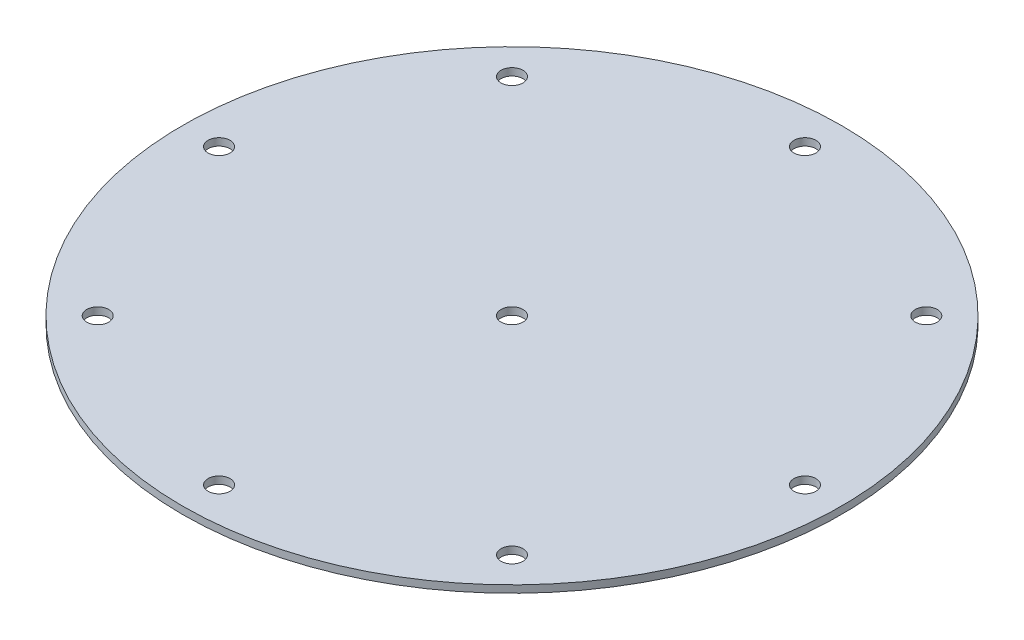
from build123d import *

# Parameters (mm, degrees)
SKETCH1_R           = 90
SKETCH1_R_2         = 3
BOSS_EXTRUDE1_DEPTH = 2


with BuildPart() as part:
    # Sketch1 → Boss-Extrude1 (new body)
    with BuildSketch(Plane(origin=(0, 0, 0), x_dir=(1, 0, 0), z_dir=(0, 1, 0))):
        Circle(SKETCH1_R)
        Circle(SKETCH1_R_2, mode=Mode.SUBTRACT)
        with Locations((0, 80)):
            Circle(SKETCH1_R_2, mode=Mode.SUBTRACT)
        with Locations((56.568542495, 56.568542495)):
            Circle(SKETCH1_R_2, mode=Mode.SUBTRACT)
        with Locations((80, 0)):
            Circle(SKETCH1_R_2, mode=Mode.SUBTRACT)
        with Locations((56.568542495, -56.568542495)):
            Circle(SKETCH1_R_2, mode=Mode.SUBTRACT)
        with Locations((0, -80)):
            Circle(SKETCH1_R_2, mode=Mode.SUBTRACT)
        with Locations((-56.568542495, -56.568542495)):
            Circle(SKETCH1_R_2, mode=Mode.SUBTRACT)
        with Locations((-80, 0)):
            Circle(SKETCH1_R_2, mode=Mode.SUBTRACT)
        with Locations((-56.568542495, 56.568542495)):
            Circle(SKETCH1_R_2, mode=Mode.SUBTRACT)
    extrude(amount=BOSS_EXTRUDE1_DEPTH)


solid = part.part
